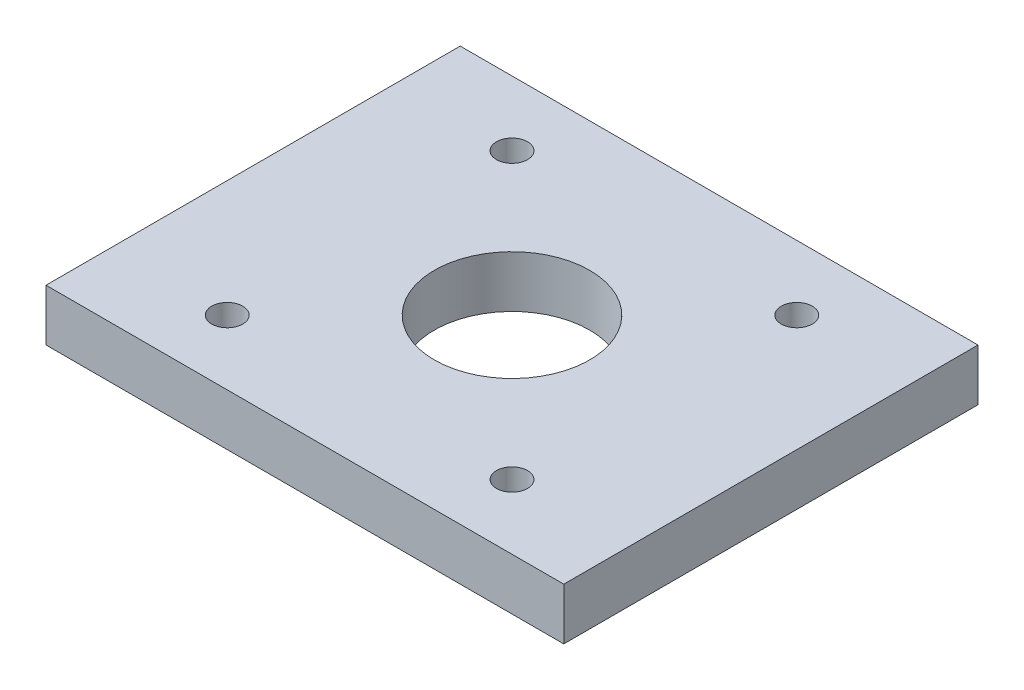
from build123d import *

# Parameters (mm, degrees)
SKETCH1_W                  = 200
SKETCH1_H                  = 160
BASE_DEPTH                 = 20
SKETCH2_R                  = 30
ACTUATOR_CUT_DEPTH         = 40
F_12_0MM_DOWEL_HOLE1_D     = 12
F_12_0MM_DOWEL_HOLE1_DEPTH = 20


with BuildPart() as part:
    # Sketch1 → base (new body)
    with BuildSketch(Plane(origin=(0, 0, 0), x_dir=(1, 0, 0), z_dir=(0, 1, 0))):
        Rectangle(SKETCH1_W, SKETCH1_H)
    extrude(amount=BASE_DEPTH)

    # Sketch2 → actuator cut (cut)
    with BuildSketch(Plane(origin=(0, 20, 0), x_dir=(1, 0, 0), z_dir=(0, 1, 0))):
        Circle(SKETCH2_R)
    extrude(amount=-ACTUATOR_CUT_DEPTH, mode=Mode.SUBTRACT)

    # Ø12.0mm Dowel Hole1
    with Locations(Plane(origin=(55, 20, -55), x_dir=(0, 0, 1), z_dir=(0, 1, 0))):
        with Locations((0, 0), (0, -110), (110, -110), (110, 0)):
            Hole(F_12_0MM_DOWEL_HOLE1_D / 2, depth=F_12_0MM_DOWEL_HOLE1_DEPTH)


solid = part.part
